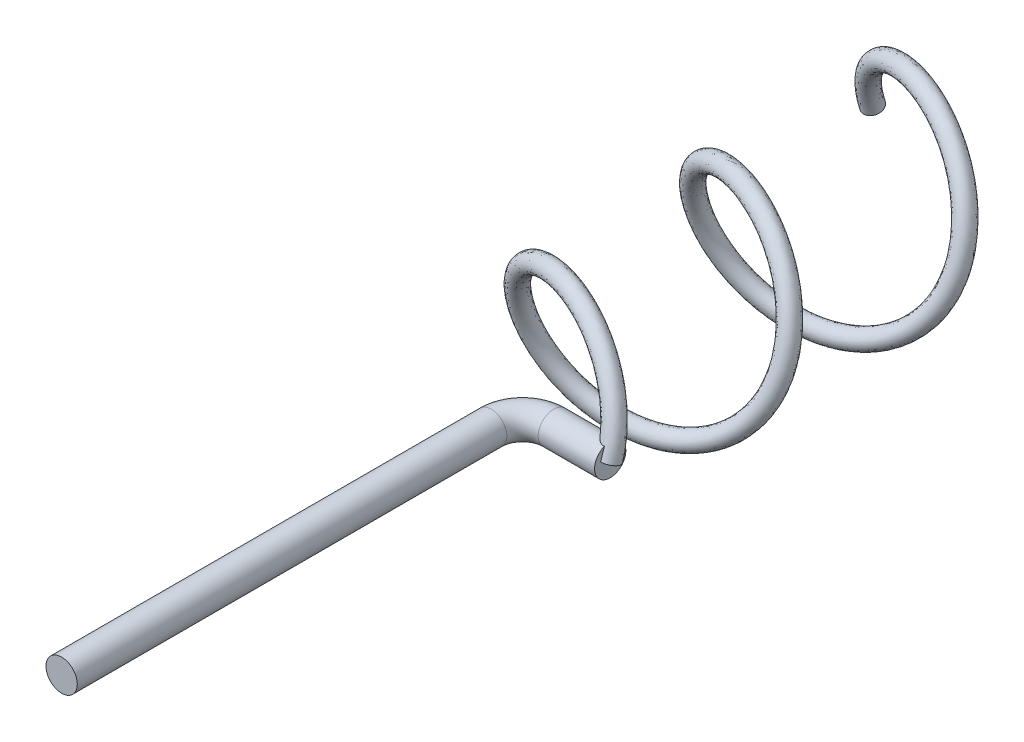
from build123d import *

# Parameters (mm, degrees)
SWEEP2_PROFILE_R   = 2.5
SWEEP3_PITCH       = 28
SWEEP3_HEIGHT      = 70
SWEEP3_RADIUS      = 14
SWEEP3_START_ANGLE = -180
SWEEP3_PROFILE_R   = 1.5


with BuildPart() as part:
    # Sweep2: sweep along a path in Sketch4
    with BuildLine(Plane(origin=(0, 0, 0), x_dir=(1, 0, 0), z_dir=(0, 1, 0))) as sweep2_path:
        Line((0, -143.484374277), (0, -74.903565526))
        ThreePointArc((0, -74.903565526), (1.464466094, -71.36803162), (5, -69.903565526))
        Line((5, -69.903565526), (14, -69.903565526))
    # Sweep2 profile (on start of the path) → Sweep2 (sweep)
    with BuildSketch(Plane(origin=(0, 0, 143.484374277), x_dir=(-1, 0, 0), z_dir=(0, 0, -1))):
        Circle(SWEEP2_PROFILE_R)
    sweep(path=sweep2_path.line)

    # Sweep3: sweep along a helix
    with BuildLine() as sweep3_path:
        add(Helix(SWEEP3_PITCH, SWEEP3_HEIGHT, SWEEP3_RADIUS, center=(0, 0, 0), direction=(0, 0, 1), lefthand=True, mode=Mode.PRIVATE).rotate(Axis((0, 0, 0), (0, 0, 1)), SWEEP3_START_ANGLE))
    # Sweep3 profile (on start of the path) → Sweep3 (sweep)
    with BuildSketch(Plane(origin=(-14, 0, 0), x_dir=(0, -0.303314471, 0.952890514), z_dir=(0, 0.952890514, 0.303314471))):
        Circle(SWEEP3_PROFILE_R)
    sweep(path=sweep3_path.line, is_frenet=True)


solid = part.part
